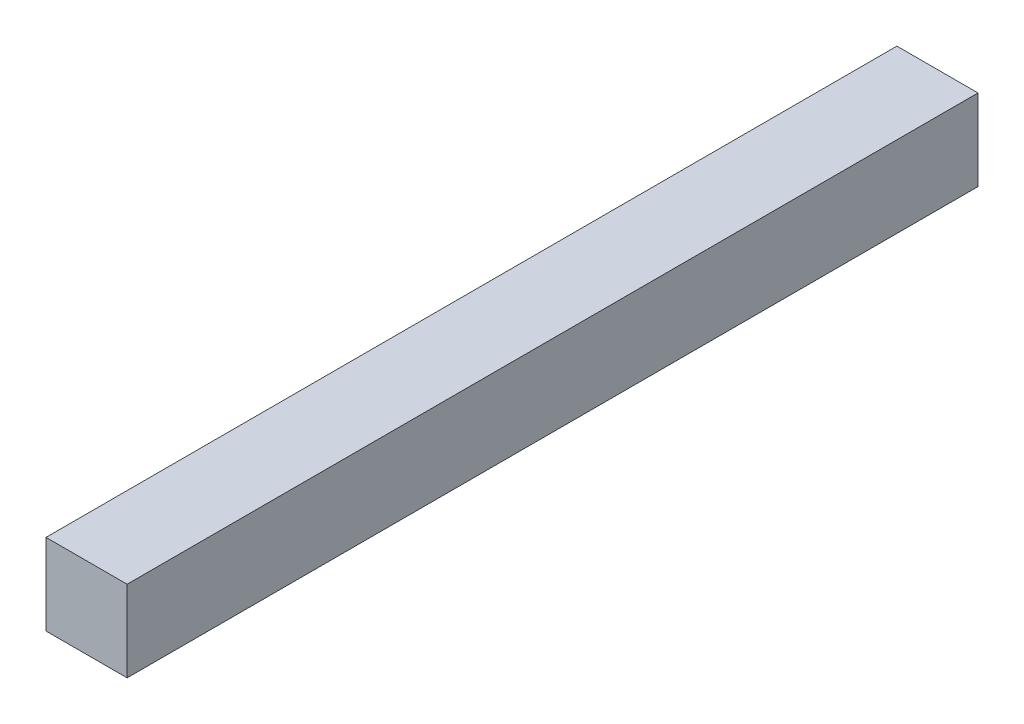
from build123d import *

# Parameters (mm, degrees)
SKETCH1_W           = 20
SKETCH1_H           = 20
BOSS_EXTRUDE1_DEPTH = 209.8


with BuildPart() as part:
    # Sketch1 → Boss-Extrude1 (new body)
    with BuildSketch(Plane.XY):
        with Locations((-123.2, 15.2)):
            Rectangle(SKETCH1_W, SKETCH1_H)
    extrude(amount=BOSS_EXTRUDE1_DEPTH)


solid = part.part
